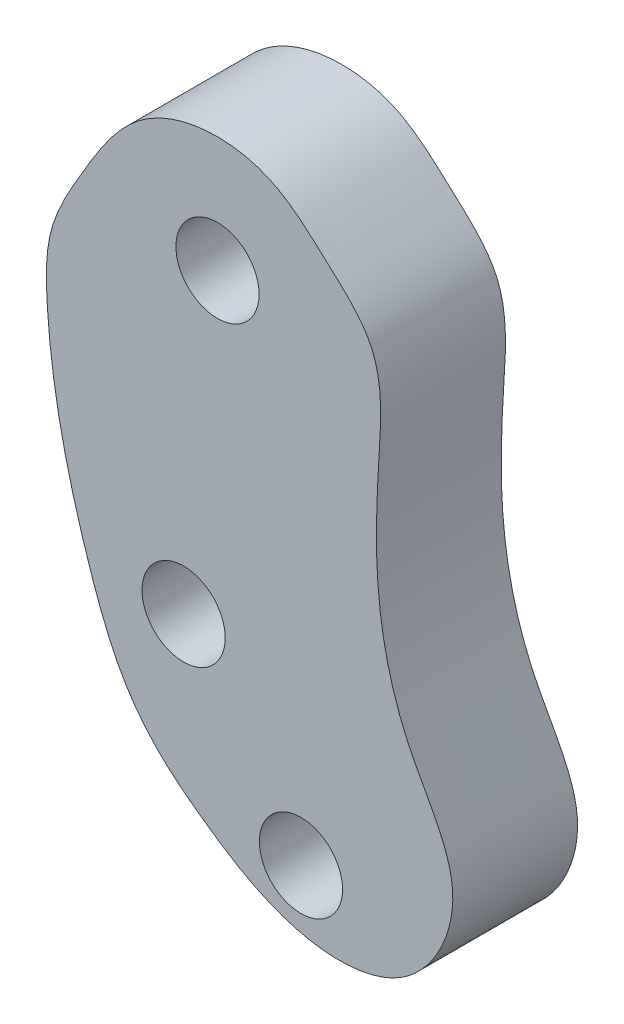
from build123d import *

# Parameters (mm, degrees)
SKETCH1_R           = 1
BOSS_EXTRUDE1_DEPTH = 3


with BuildPart() as part:
    # Sketch1 → Boss-Extrude1 (new body)
    with BuildSketch(Plane.XY):
        with BuildLine():
            add(Edge.make_bspline(
                [(-12.48112564, 34.03710972), (-12.302085728, 34.174245405), (-11.366685018, 34.730779027), (-9.450787623, 34.741156546), (-8.01266663, 33.383444608), (-6.56574966, 32.107683605), (-6.732822806, 29.72932544), (-6.856113521, 27.107591861), (-6.222641841, 24.263531887), (-4.414595607, 21.857604516), (-5.784947897, 19.055675592), (-8.671405591, 18.790908462), (-10.562276093, 19.942452997), (-11.964642166, 21.035426328), (-12.977887528, 22.249955145), (-13.70125892, 24.142110668), (-14.389484989, 26.545414253), (-14.704000852, 28.716062044), (-14.735859832, 30.755676771), (-13.782622679, 32.386488529), (-13.060804235, 33.593104689), (-12.48112564, 34.03710972)],
                knots=[0, 0, 0, 0, 0.016845482, 0.07993598, 0.121675203, 0.162279018, 0.21497294, 0.284203251, 0.360988155, 0.426471168, 0.491283962, 0.546186763, 0.6203805, 0.650124732, 0.677947593, 0.736182549, 0.798041578, 0.862967677, 0.89908385, 0.945459282, 1, 1, 1, 1], degree=3))
        make_face()
        with Locations((-10.593846929, 31.863789047)):
            Circle(SKETCH1_R, mode=Mode.SUBTRACT)
        with Locations((-8.587203419, 20.479070181)):
            Circle(SKETCH1_R, mode=Mode.SUBTRACT)
        with Locations((-11.408582392, 24.303513571)):
            Circle(SKETCH1_R, mode=Mode.SUBTRACT)
    extrude(amount=BOSS_EXTRUDE1_DEPTH)


solid = part.part
